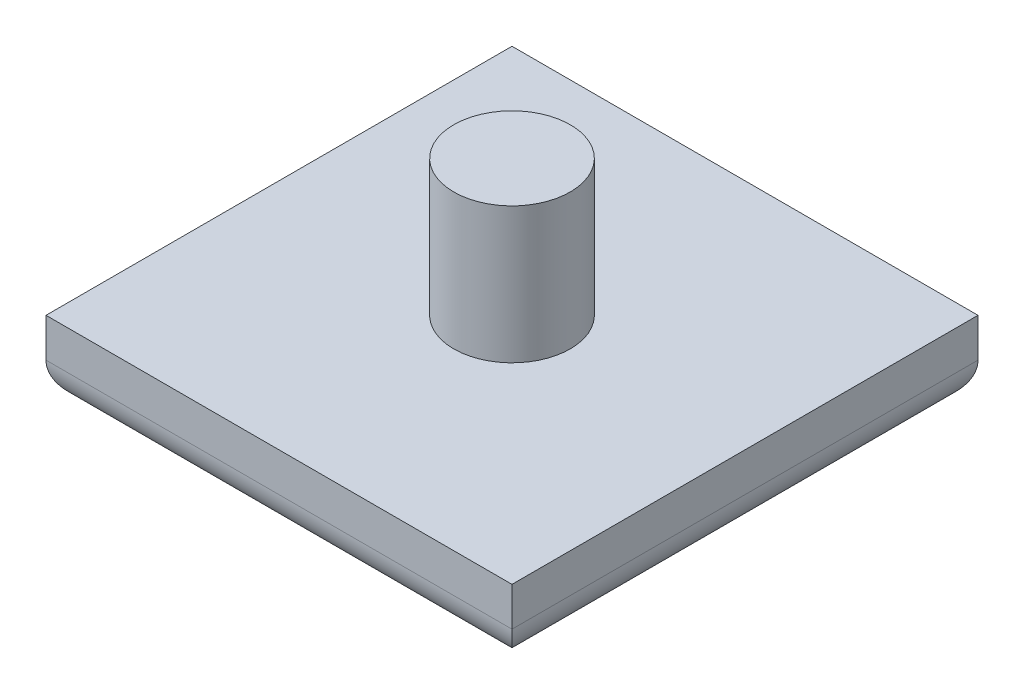
from build123d import *

# Parameters (mm, degrees)
SKETCH1_W           = 30.48
SKETCH1_H           = 30.48
BOSS_EXTRUDE1_DEPTH = 5.08
SKETCH2_R           = 3.81
BOSS_EXTRUDE2_DEPTH = 8.89
FILLET1_R           = 2.54
SKETCH3_R           = 2.54
CUT_EXTRUDE1_DEPTH  = 12.7


with BuildPart() as part:
    # Sketch1 → Boss-Extrude1 (new body)
    with BuildSketch(Plane(origin=(0, 0, 0), x_dir=(1, 0, 0), z_dir=(0, 1, 0))):
        Rectangle(SKETCH1_W, SKETCH1_H)
    extrude(amount=BOSS_EXTRUDE1_DEPTH)

    # Sketch2 → Boss-Extrude2 (add)
    with BuildSketch(Plane(origin=(0, 5.08, 0), x_dir=(1, 0, 0), z_dir=(0, 1, 0))):
        Circle(SKETCH2_R)
    extrude(amount=BOSS_EXTRUDE2_DEPTH)

    # Fillet1
    fillet1_edges = [part.edges().sort_by_distance(p)[0] for p in [
        (0, 0, 15.24),
        (-15.24, 0, 0),
        (0, 0, -15.24),
        (15.24, 0, 0),
    ]]
    fillet(fillet1_edges, radius=FILLET1_R)

    # Sketch3 → Cut-Extrude1 (cut)
    with BuildSketch(Plane.XZ):
        Circle(SKETCH3_R)
    extrude(amount=-CUT_EXTRUDE1_DEPTH, mode=Mode.SUBTRACT)


solid = part.part
